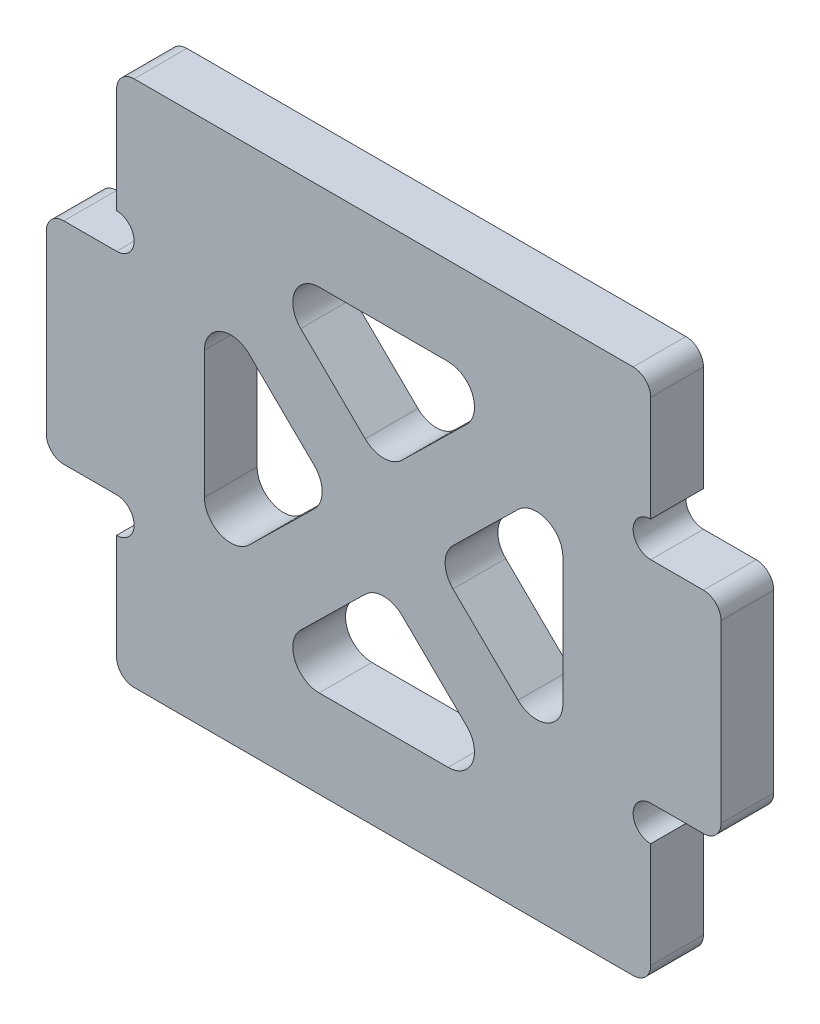
from build123d import *

# Parameters (mm, degrees)
EXTRUDE_1_DEPTH     = 3
SKETCH_2_R          = 1
CUT_EXTRUDE_1_DEPTH = 4
SKETCH_3_W          = 20.4
SKETCH_3_H          = 20
CUT_EXTRUDE_2_DEPTH = 4
EXTRUDE_1_2_DEPTH   = 3
FILLET_1_R          = 1
FILLET_2_R          = 1.5


with BuildPart() as part:
    # 草图1 → Extrude 1 (new body)
    with BuildSketch(Plane.XY):
        Polygon((15.2, -15), (-15.2, -15), (-15.2, -6), (-19.2, -6), (-19.2, 6), (-15.2, 6), (-15.2, 15), (15.2, 15), (15.2, 6), (19.2, 6), (19.2, -6), (15.2, -6), align=None)
    extrude(amount=EXTRUDE_1_DEPTH)

    # 草图2 → 切除-拉伸1 (cut, through all)
    with BuildSketch(Plane.XY.offset(3)):
        with Locations((-15.2, 7)):
            Circle(SKETCH_2_R)
        with Locations((-15.2, -7)):
            Circle(SKETCH_2_R)
        with Locations((15.2, -7)):
            Circle(SKETCH_2_R)
        with Locations((15.2, 7)):
            Circle(SKETCH_2_R)
    extrude(amount=-CUT_EXTRUDE_1_DEPTH, mode=Mode.SUBTRACT)

    # 草图3 → 切除-拉伸2 (cut, through all)
    with BuildSketch(Plane.XY.offset(3)):
        Rectangle(SKETCH_3_W, SKETCH_3_H)
    extrude(amount=-CUT_EXTRUDE_2_DEPTH, mode=Mode.SUBTRACT)

    # 草图4 → Extrude 1 2 (add)
    with BuildSketch(Plane.XY.offset(3)):
        Polygon((-11.600142822, 8.571854322), (8.799857178, -11.428145678), (11.600142822, -8.571854322), (-8.799857178, 11.428145678), align=None)
        Polygon((-8.799857178, -11.428145678), (11.600142822, 8.571854322), (8.799857178, 11.428145678), (-11.600142822, -8.571854322), align=None)
    extrude(amount=-EXTRUDE_1_2_DEPTH)

    # 圆角1
    fillet_1_edges = [part.edges().sort_by_distance(p)[0] for p in [
        (-15.2, 15, 1.5),
        (15.2, 15, 1.5),
        (19.2, 6, 1.5),
        (19.2, -6, 1.5),
        (15.2, -15, 1.5),
        (-15.2, -15, 1.5),
        (-19.2, -6, 1.5),
        (-19.2, 6, 1.5),
    ]]
    fillet(fillet_1_edges, radius=FILLET_1_R)

    # 圆角2
    fillet_2_edges = [part.edges().sort_by_distance(p)[0] for p in [
        (-2.856851414, 0, 1.5),
        (0, 2.800834719, 1.5),
        (2.856851414, 0, 1.5),
        (0, -2.800834719, 1.5),
        (-7.343148586, -10, 1.5),
        (7.343148586, -10, 1.5),
        (10.2, 7.199165281, 1.5),
        (10.2, -7.199165281, 1.5),
        (7.343148586, 10, 1.5),
        (-7.343148586, 10, 1.5),
        (-10.2, -7.199165281, 1.5),
        (-10.2, 7.199165281, 1.5),
    ]]
    fillet(fillet_2_edges, radius=FILLET_2_R)


solid = part.part
